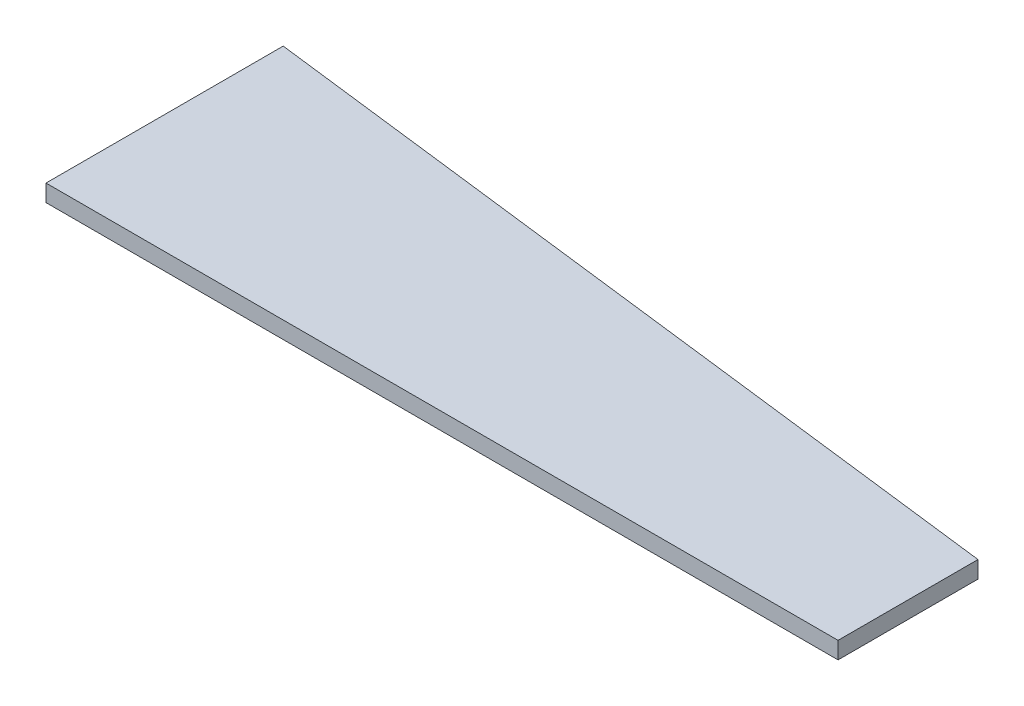
from build123d import *

# Parameters (mm, degrees)
BOSS_EXTRUDE1_DEPTH = 5.7


with BuildPart() as part:
    # Sketch1 → Boss-Extrude1 (new body)
    with BuildSketch(Plane(origin=(0, 0, 0), x_dir=(1, 0, 0), z_dir=(0, 1, 0))):
        Polygon((138.036858359, -41.338766256), (138.036858359, 5.661233744), (-127.963141641, 38.321926944), (-127.963141641, -41.338766256), align=None)
    extrude(amount=BOSS_EXTRUDE1_DEPTH)


solid = part.part
